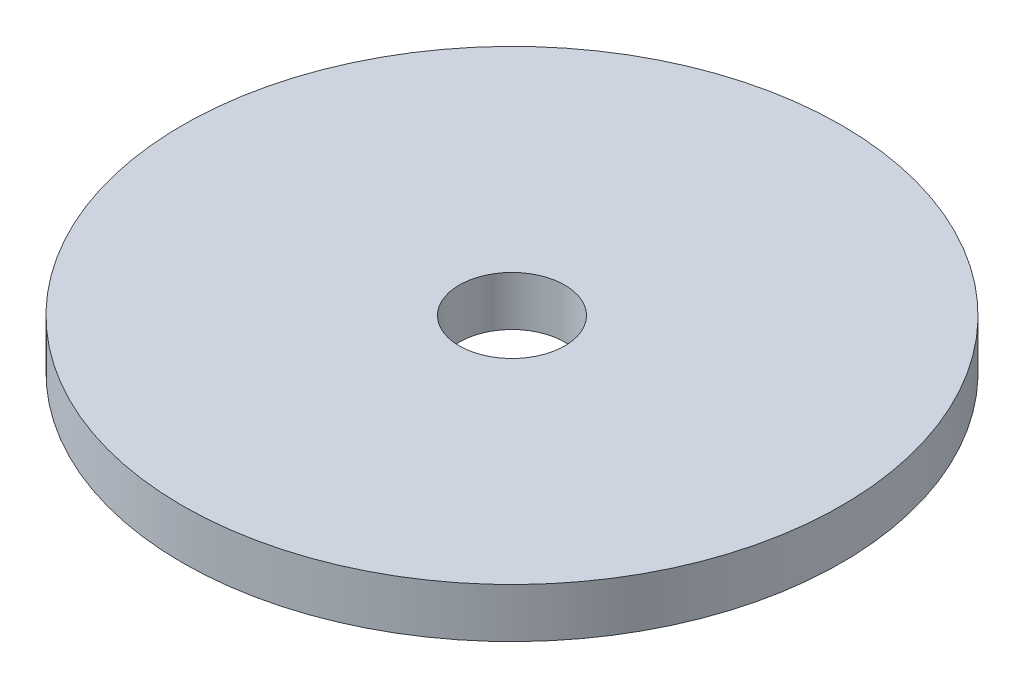
from build123d import *

# Parameters (mm, degrees)
CROQUIS1_R              = 20
CROQUIS1_R_2            = 3.2
SALIENTE_EXTRUIR1_DEPTH = 3


with BuildPart() as part:
    # Croquis1 → Saliente-Extruir1 (new body)
    with BuildSketch(Plane(origin=(0, 0, 0), x_dir=(1, 0, 0), z_dir=(0, 1, 0))):
        Circle(CROQUIS1_R)
        Circle(CROQUIS1_R_2, mode=Mode.SUBTRACT)
    extrude(amount=SALIENTE_EXTRUIR1_DEPTH)


solid = part.part
